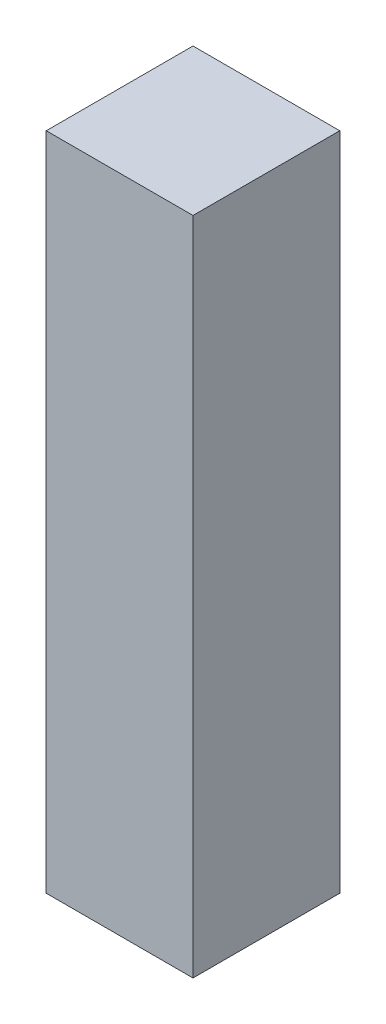
from build123d import *

# Parameters (mm, degrees)
SKETCH2_W           = 3.175
SKETCH2_H           = 14.2875
BOSS_EXTRUDE1_DEPTH = 3.175


with BuildPart() as part:
    # Sketch2 → Boss-Extrude1 (new body)
    with BuildSketch(Plane.XY):
        Rectangle(SKETCH2_W, SKETCH2_H)
    extrude(amount=BOSS_EXTRUDE1_DEPTH)


solid = part.part
